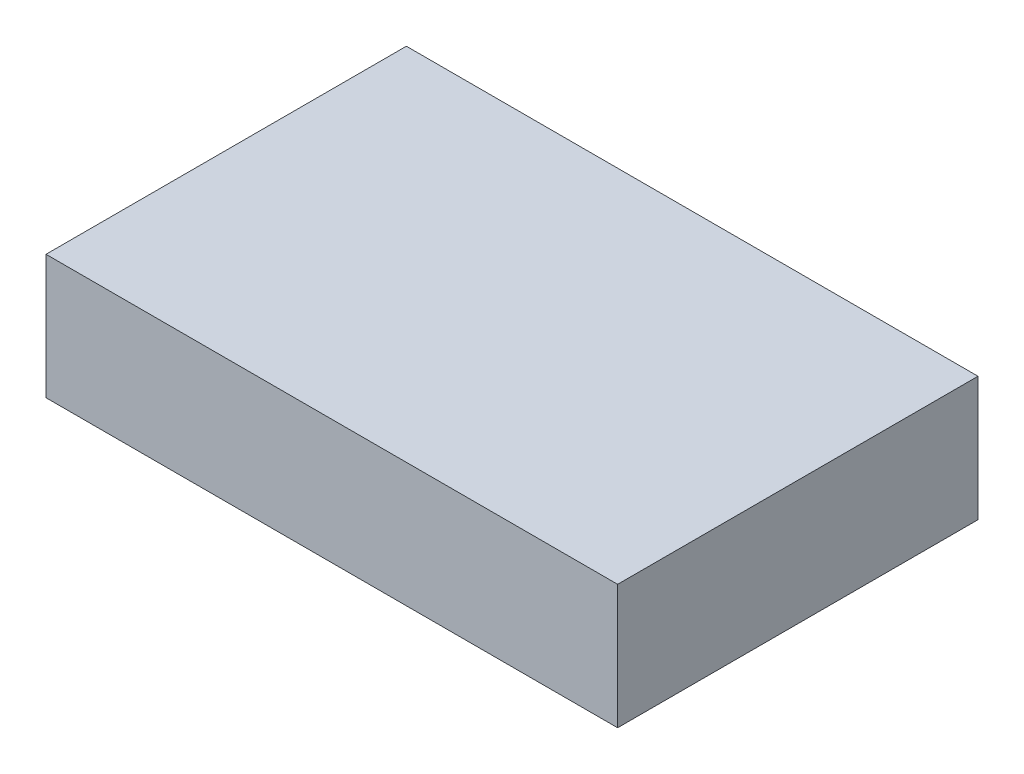
from build123d import *

# Parameters (mm, degrees)
SKETCH1_W           = 58.42
SKETCH1_H           = 36.83
BOSS_EXTRUDE1_DEPTH = 12.7


with BuildPart() as part:
    # Sketch1 → Boss-Extrude1 (new body)
    with BuildSketch(Plane(origin=(0, 0, 0), x_dir=(1, 0, 0), z_dir=(0, 1, 0))):
        with Locations((29.21, 18.415)):
            Rectangle(SKETCH1_W, SKETCH1_H)
    extrude(amount=BOSS_EXTRUDE1_DEPTH)


solid = part.part
